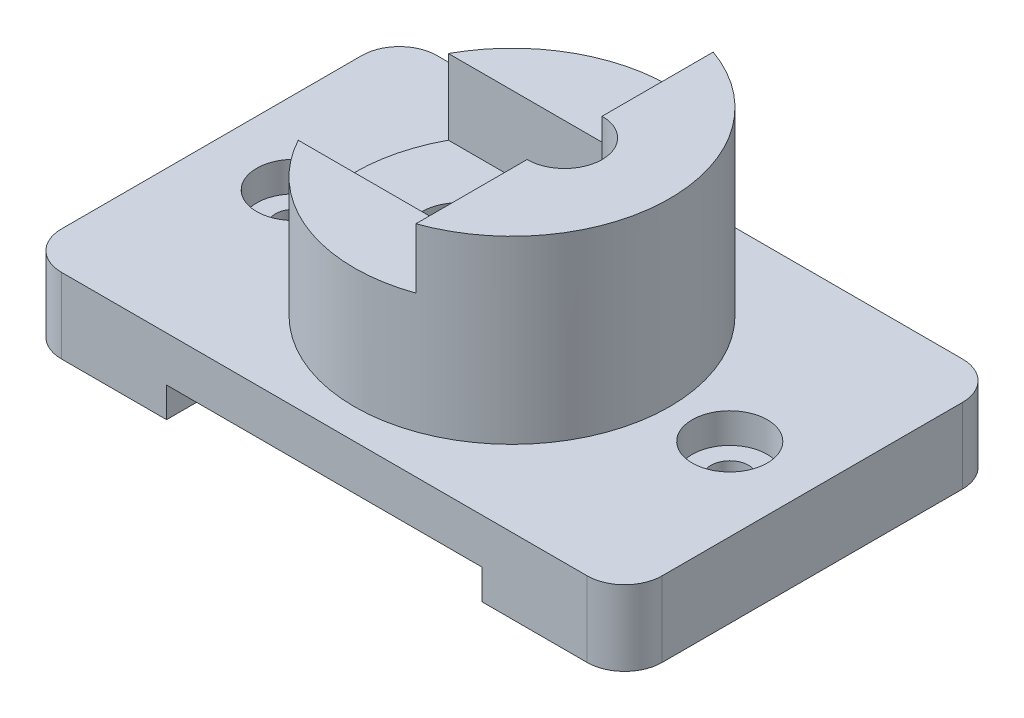
from build123d import *

# Parameters (mm, degrees)
EXTRUDE_1_DEPTH          = 10
SKETCH_2_R               = 21
EXTRUDE_2_DEPTH          = 34
CUT_EXTRUDE_1_DEPTH      = 35
CUT_EXTRUDE_2_DEPTH      = 8
CUT_EXTRUDE_3_DEPTH      = 10
SKETCH_6_R               = 5
CUT_EXTRUDE_4_DEPTH      = 4
SKETCH_7_R               = 2.5
CUT_EXTRUDE_5_DEPTH      = 7
SKETCH_8_W               = 42
SKETCH_8_H               = 4
CUT_EXTRUDE_6_DEPTH      = 26
CUT_EXTRUDE_6_DEPTH_BACK = 26


with BuildPart() as part:
    # 草图1 → 凸台-拉伸1 (new body)
    with BuildSketch(Plane(origin=(0, 0, 0), x_dir=(1, 0, 0), z_dir=(0, 1, 0))):
        with BuildLine():
            Line((-35, 25), (35, 25))
            ThreePointArc((35, 25), (38.535533906, 23.535533906), (40, 20))
            Line((40, 20), (40, -20))
            ThreePointArc((40, -20), (38.535533906, -23.535533906), (35, -25))
            Line((35, -25), (-35, -25))
            ThreePointArc((-35, -25), (-38.535533906, -23.535533906), (-40, -20))
            Line((-40, -20), (-40, 20))
            ThreePointArc((-40, 20), (-38.535533906, 23.535533906), (-35, 25))
        make_face()
    extrude(amount=EXTRUDE_1_DEPTH)

    # 草图2 → 凸台-拉伸2 (add)
    with BuildSketch(Plane(origin=(0, 0, 0), x_dir=(1, 0, 0), z_dir=(0, 1, 0))):
        Circle(SKETCH_2_R)
    extrude(amount=EXTRUDE_2_DEPTH)

    # 草图3 → 切除-拉伸1 (cut, through all)
    with BuildSketch(Plane(origin=(0, 34, 0), x_dir=(1, 0, 0), z_dir=(0, 1, 0))):
        with BuildLine():
            Line((-7, 5), (7, 5))
            ThreePointArc((7, 5), (12, 0), (7, -5))
            Line((7, -5), (-7, -5))
            ThreePointArc((-7, -5), (-12, 0), (-7, 5))
        make_face()
    extrude(amount=-CUT_EXTRUDE_1_DEPTH, mode=Mode.SUBTRACT)

    # 草图4 → 切除-拉伸2 (cut)
    with BuildSketch(Plane(origin=(0, 34, 0), x_dir=(1, 0, 0), z_dir=(0, 1, 0))):
        with BuildLine():
            Line((7, 19.798989873), (7, -19.798989873))
            ThreePointArc((7, -19.798989873), (-21, 0), (7, 19.798989873))
        make_face()
    extrude(amount=-CUT_EXTRUDE_2_DEPTH, mode=Mode.SUBTRACT)

    # 草图5 → 切除-拉伸3 (cut)
    with BuildSketch(Plane(origin=(0, 26, 0), x_dir=(1, 0, 0), z_dir=(0, 1, 0))):
        with BuildLine():
            Line((-18.466185313, 10), (7, 10))
            Line((7, 10), (7, -10))
            Line((7, -10), (-18.466185313, -10))
            ThreePointArc((-18.466185313, -10), (-21, 0), (-18.466185313, 10))
        make_face()
    extrude(amount=-CUT_EXTRUDE_3_DEPTH, mode=Mode.SUBTRACT)

    # 草图6 → 切除-拉伸4 (cut)
    with BuildSketch(Plane(origin=(0, 10, 0), x_dir=(1, 0, 0), z_dir=(0, 1, 0))):
        with Locations((-29, 0)):
            Circle(SKETCH_6_R)
    cut_extrude_4 = extrude(amount=-CUT_EXTRUDE_4_DEPTH, mode=Mode.SUBTRACT)

    # 草图7 → 切除-拉伸5 (cut, through all)
    with BuildSketch(Plane(origin=(0, 6, 0), x_dir=(1, 0, 0), z_dir=(0, 1, 0))):
        with Locations((-29, 0)):
            Circle(SKETCH_7_R)
    cut_extrude_5 = extrude(amount=-CUT_EXTRUDE_5_DEPTH, mode=Mode.SUBTRACT)

    # 镜向1: 切除-拉伸4, 切除-拉伸5 across plane
    add(cut_extrude_4.mirror(Plane(origin=(0, 0, 0), x_dir=(0, 0, 1), z_dir=(1, 0, 0))), mode=Mode.SUBTRACT)
    add(cut_extrude_5.mirror(Plane(origin=(0, 0, 0), x_dir=(0, 0, 1), z_dir=(1, 0, 0))), mode=Mode.SUBTRACT)

    # 草图8 → 切除-拉伸6 (cut, two sides)
    with BuildSketch(Plane.XY) as cut_extrude_6_sk:
        with Locations((0, 2)):
            Rectangle(SKETCH_8_W, SKETCH_8_H)
    extrude(amount=CUT_EXTRUDE_6_DEPTH, mode=Mode.SUBTRACT)
    extrude(cut_extrude_6_sk.sketch, amount=-CUT_EXTRUDE_6_DEPTH_BACK, mode=Mode.SUBTRACT)


solid = part.part
